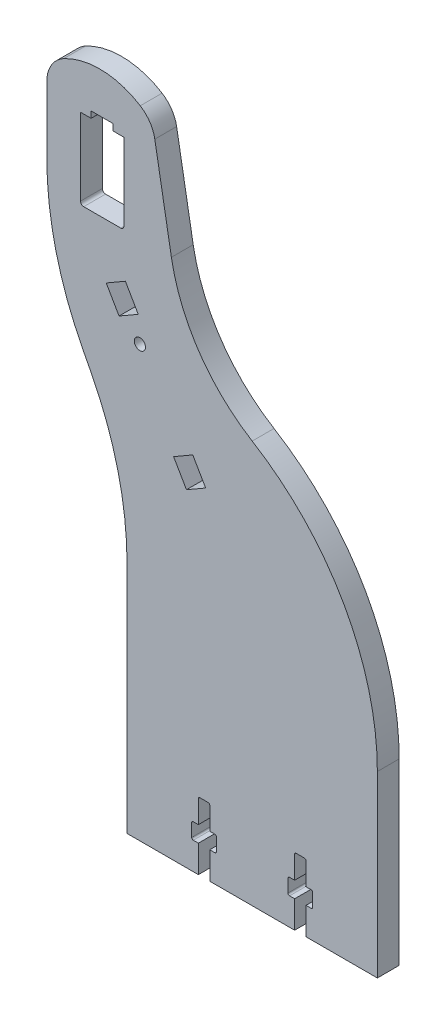
from build123d import *

# Parameters (mm, degrees)
BOSS_EXTRUDE1_DEPTH = 6.8
SKETCH2_W           = 2.085
SKETCH2_H           = 5
SKETCH2_W_2         = 3.55
SKETCH2_H_2         = 8.5
SKETCH2_H_3         = 7.5
CUT_EXTRUDE1_DEPTH  = 6.8
CUT_EXTRUDE2_DEPTH  = 6.8
SKETCH4_R           = 1.75
CUT_EXTRUDE3_DEPTH  = 6.8
FILLET1_R           = 1
FILLET2_R           = 0.5


with BuildPart() as part:
    # Sketch1 → Boss-Extrude1 (new body)
    with BuildSketch(Plane.XY):
        with BuildLine():
            Line((-103, 169.798422238), (-103, 190.436528082))
            ThreePointArc((-103, 190.436528082), (-101.582115005, 195.569490389), (-97.730539592, 199.246862648))
            ThreePointArc((-97.730539592, 199.246862648), (-85.697338027, 202.057615588), (-73.881600239, 198.440073256))
            ThreePointArc((-73.881600239, 198.440073256), (-70.90110432, 195.553704599), (-69.348658208, 191.706057135))
            Line((-69.348658208, 191.706057135), (-64.181209637, 162.4))
            ThreePointArc((-64.181209637, 162.4), (-55.56310459, 141.196422986), (-39, 125.4))
            ThreePointArc((-39, 125.4), (-10.413345727, 95.649656796), (0, 55.726706578))
            Line((0, 55.726706578), (0, 0))
            Line((0, 0), (-78, 0))
            Line((-78, 0), (-78, 72.818559508))
            ThreePointArc((-78, 72.818559508), (-80.849795474, 96.521676613), (-89.23675521, 118.873813001))
            Line((-89.23675521, 118.873813001), (-91.76324479, 123.743168745))
            ThreePointArc((-91.76324479, 123.743168745), (-100.150204526, 146.095305133), (-103, 169.798422238))
        make_face()
    extrude(amount=BOSS_EXTRUDE1_DEPTH)

    # Sketch2 → Cut-Extrude1 (cut)
    with BuildSketch(Plane.XY.offset(6.8)):
        with Locations((-51.1825, 11)):
            Rectangle(SKETCH2_W, SKETCH2_H)
        with Locations((-54, 11)):
            Rectangle(SKETCH2_W_2, SKETCH2_H)
        with Locations((-56.8175, 11)):
            Rectangle(SKETCH2_W, SKETCH2_H)
        with Locations((-54, 4.25)):
            Rectangle(SKETCH2_W_2, SKETCH2_H_2)
        with Locations((-54, 17.25)):
            Rectangle(SKETCH2_W_2, SKETCH2_H_3)
        with Locations((-26.8175, 11)):
            Rectangle(SKETCH2_W, SKETCH2_H)
        with Locations((-21.1825, 11)):
            Rectangle(SKETCH2_W, SKETCH2_H)
        with Locations((-24, 17.25)):
            Rectangle(SKETCH2_W_2, SKETCH2_H_3)
        with Locations((-24, 11)):
            Rectangle(SKETCH2_W_2, SKETCH2_H)
        with Locations((-24, 4.25)):
            Rectangle(SKETCH2_W_2, SKETCH2_H_2)
    extrude(amount=-CUT_EXTRUDE1_DEPTH, mode=Mode.SUBTRACT)

    # Sketch3 → Cut-Extrude2 (cut)
    with BuildSketch(Plane.XY.offset(6.8)):
        Polygon((-89.2, 187.4), (-89.2, 189.4), (-82.3, 189.4), (-82.3, 187.4), (-79, 187.4), (-79, 162.4), (-92.5, 162.4), (-92.5, 187.4), align=None)
    extrude(amount=-CUT_EXTRUDE2_DEPTH, mode=Mode.SUBTRACT)

    # Sketch4 → Cut-Extrude3 (cut)
    with BuildSketch(Plane.XY.offset(6.8)):
        with Locations((-74.000212357, 134.060889132)):
            Circle(SKETCH4_R)
        Polygon((-84.488, 145.326270189), (-80.488, 138.398066959), (-74.512424714, 141.848066959), (-78.512424714, 148.776270189), align=None)
        Polygon((-63.488, 108.95320323), (-59.488, 102.025), (-53.512424714, 105.475), (-57.512424714, 112.40320323), align=None)
    extrude(amount=-CUT_EXTRUDE3_DEPTH, mode=Mode.SUBTRACT)

    # Fillet1
    fillet1_edges = [part.edges().sort_by_distance(p)[0] for p in [
        (-79, 162.4, 3.4),
        (-92.5, 162.4, 3.4),
    ]]
    fillet(fillet1_edges, radius=FILLET1_R)

    # Fillet2
    fillet2_edges = [part.edges().sort_by_distance(p)[0] for p in [
        (-50.14, 13.5, 3.4),
        (-50.14, 8.5, 3.4),
        (-57.86, 8.5, 3.4),
        (-57.86, 13.5, 3.4),
        (-55.775, 21, 3.4),
        (-52.225, 21, 3.4),
        (-27.86, 8.5, 3.4),
        (-27.86, 13.5, 3.4),
        (-25.775, 21, 3.4),
        (-22.225, 21, 3.4),
        (-20.14, 13.5, 3.4),
        (-20.14, 8.5, 3.4),
    ]]
    fillet(fillet2_edges, radius=FILLET2_R)


solid = part.part
